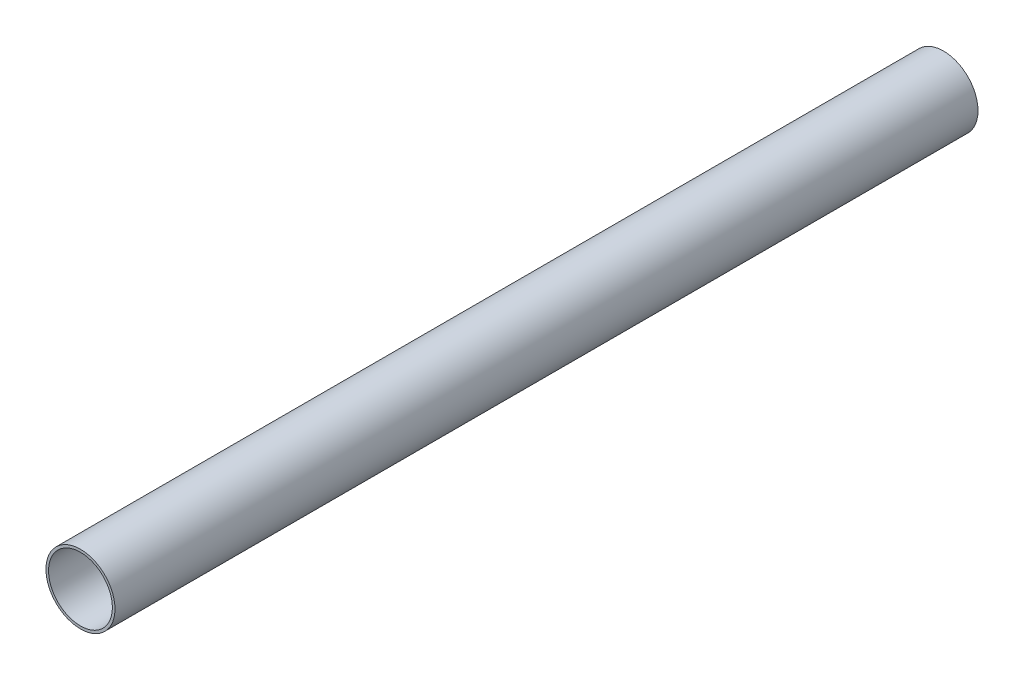
from build123d import *

# Parameters (mm, degrees)
SKETCH_1_R      = 20
SKETCH_1_R_2    = 18.5
EXTRUDE_1_DEPTH = 500


with BuildPart() as part:
    # 스케치1 → 보스-돌출1 (new body)
    with BuildSketch(Plane.XY):
        Circle(SKETCH_1_R)
        Circle(SKETCH_1_R_2, mode=Mode.SUBTRACT)
    extrude(amount=EXTRUDE_1_DEPTH)


solid = part.part
